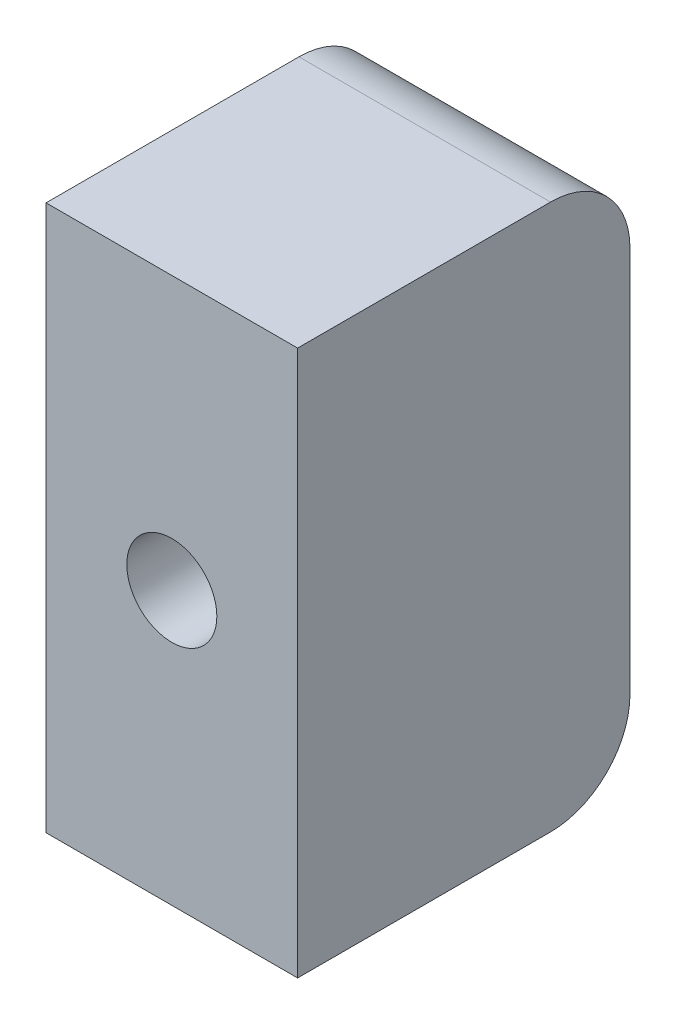
from build123d import *

# Parameters (mm, degrees)
EXTRUDE_1_DEPTH      = 19
M8X1_251_D           = 6.8
M8X1_251_DEPTH       = 28.25
M8X1_251_CSINK_D     = 8.5
M8X1_251_CSINK_ANGLE = 90
M8X1_251_TIP         = 2.042926105


with BuildPart() as part:
    # Эскиз1 → Бобышка-Вытянуть1 (new body)
    with BuildSketch(Plane(origin=(0, 0, 0), x_dir=(0, 0, -1), z_dir=(1, 0, 0))):
        with BuildLine():
            Line((-6, 9.4), (-25.1, 9.4))
            Line((-25.1, 9.4), (-25.1, 50.6))
            Line((-25.1, 50.6), (-6, 50.6))
            ThreePointArc((-6, 50.6), (-1.757359313, 48.842640687), (0, 44.6))
            Line((0, 44.6), (0, 15.4))
            ThreePointArc((0, 15.4), (-1.757359313, 11.157359313), (-6, 9.4))
        make_face()
    extrude(amount=-EXTRUDE_1_DEPTH)

    # Отверстие обработанное метчиком M8x1.251
    with Locations(Plane(origin=(0, 0, 0), x_dir=(-1, 0, 0), z_dir=(0, 0, -1))):
        with Locations((9.5, 30)):
            CounterSinkHole(M8X1_251_D / 2, M8X1_251_CSINK_D / 2, depth=M8X1_251_DEPTH, counter_sink_angle=M8X1_251_CSINK_ANGLE)
            with Locations((0, 0, -(M8X1_251_DEPTH + M8X1_251_TIP / 2))):  # 118° drill point
                Cone(0, M8X1_251_D / 2, M8X1_251_TIP, mode=Mode.SUBTRACT)


solid = part.part
